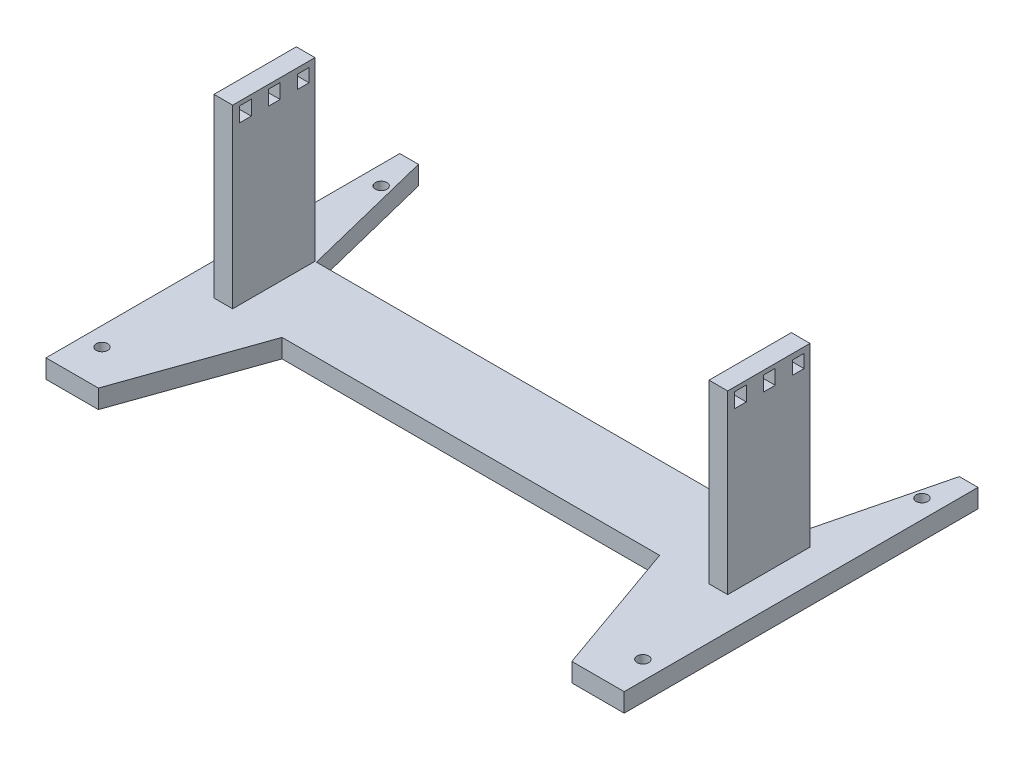
from build123d import *

# Parameters (mm, degrees)
SKETCH_6_R          = 1.984
EXTRUDE_2_DEPTH     = 6.35
SKETCH_7_W          = 6.35
SKETCH_7_H          = 28
EXTRUDE_3_DEPTH     = 60
SKETCH_8_W          = 4
SKETCH_8_H          = 5
SKETCH_8_H_2        = 4.5
CUT_EXTRUDE_3_DEPTH = 250


with BuildPart() as part:
    # 草图6 → 凸台-拉伸2 (new body)
    with BuildSketch(Plane(origin=(0, 3, 0), x_dir=(1, 0, 0), z_dir=(0, 1, 0))):
        Polygon((98.316405333, 0), (91.966405333, 0), (80.5, 0), (64.197651568, 46.16), (-64.197651568, 46.16), (-80.5, 0), (-91.966405333, 0), (-98.316405333, 0), (-98.316405333, 120.32), (-91.966405333, 120.32), (-80.5, 74.16), (-64.197651568, 74.16), (64.197651568, 74.16), (80.5, 74.16), (91.966405333, 120.32), (98.316405333, 120.32), align=None)
        with Locations((91.966405333, 12.7)):
            Circle(SKETCH_6_R, mode=Mode.SUBTRACT)
        with Locations((91.966405333, 107.62)):
            Circle(SKETCH_6_R, mode=Mode.SUBTRACT)
        with Locations((-91.966405333, 12.7)):
            Circle(SKETCH_6_R, mode=Mode.SUBTRACT)
        with Locations((-91.966405333, 107.62)):
            Circle(SKETCH_6_R, mode=Mode.SUBTRACT)
    extrude(amount=EXTRUDE_2_DEPTH)

    # 草图7 → 凸台-拉伸3 (add)
    with BuildSketch(Plane(origin=(0, 9.35, 0), x_dir=(1, 0, 0), z_dir=(0, 1, 0))):
        with Locations((84.175, 60.16)):
            Rectangle(SKETCH_7_W, SKETCH_7_H)
        with Locations((-84.175, 60.16)):
            Rectangle(SKETCH_7_W, SKETCH_7_H)
    extrude(amount=EXTRUDE_3_DEPTH)

    # 草图8 → 切除-拉伸3 (cut)
    with BuildSketch(Plane(origin=(87.35, 0, 0), x_dir=(0, 0, -1), z_dir=(1, 0, 0))):
        with Locations((50.49, 65.44)):
            Rectangle(SKETCH_8_W, SKETCH_8_H)
        with Locations((60.31, 65.44)):
            Rectangle(SKETCH_8_W, SKETCH_8_H)
        with Locations((70.13, 65.19)):
            Rectangle(SKETCH_8_W, SKETCH_8_H_2)
    extrude(amount=-CUT_EXTRUDE_3_DEPTH, mode=Mode.SUBTRACT)


solid = part.part
